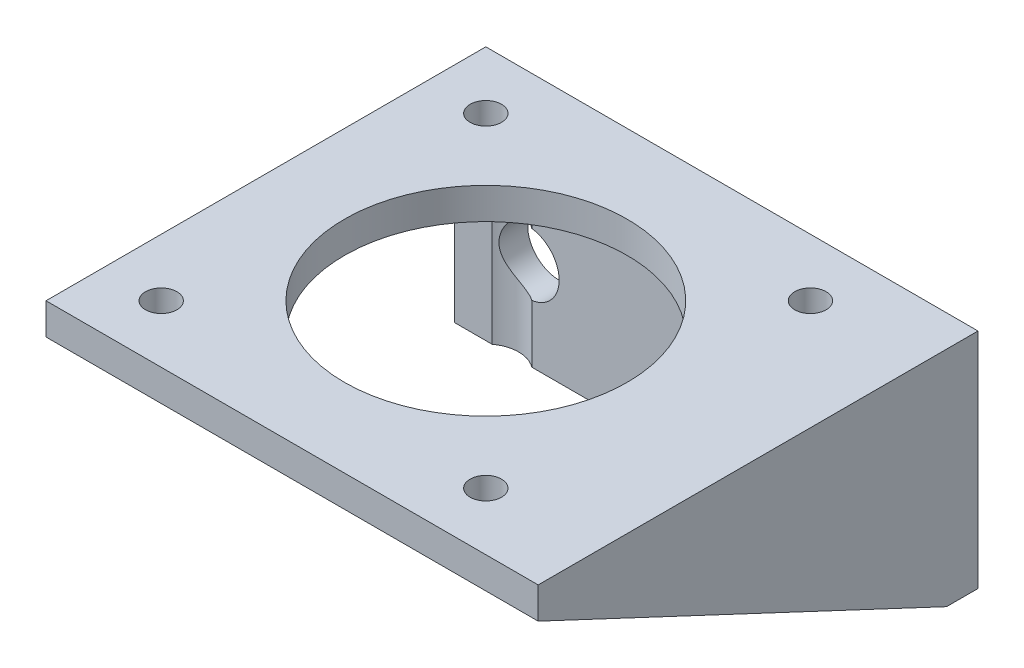
from build123d import *

# Parameters (mm, degrees)
SKETCH1_W           = 42
SKETCH1_H           = 21.3
BOSS_EXTRUDE1_DEPTH = 3
SKETCH2_R           = 3
CUT_EXTRUDE1_DEPTH  = 3
SKETCH4_W           = 42
SKETCH4_H           = 42
SKETCH4_R           = 1.5
SKETCH4_R_2         = 13.5
BOSS_EXTRUDE2_DEPTH = 3
BOSS_EXTRUDE3_DEPTH = 5
SKETCH6_R           = 3.134349401
CUT_EXTRUDE2_DEPTH  = 20


with BuildPart() as part:
    # Sketch1 → Boss-Extrude1 (new body)
    with BuildSketch(Plane.XY):
        with Locations((98.144783915, 168.215968794)):
            Rectangle(SKETCH1_W, SKETCH1_H)
    extrude(amount=BOSS_EXTRUDE1_DEPTH)

    # Sketch2 → Cut-Extrude1 (cut)
    with BuildSketch(Plane.XY.offset(3)):
        with Locations((112.144783915, 166.065968794)):
            Circle(SKETCH2_R)
        with Locations((84.144783915, 166.065968794)):
            Circle(SKETCH2_R)
    extrude(amount=-CUT_EXTRUDE1_DEPTH, mode=Mode.SUBTRACT)

    # Sketch4 → Boss-Extrude2 (add)
    with BuildSketch(Plane(origin=(0, 178.865968794, 0), x_dir=(-1, 0, 0), z_dir=(0, 1, 0))):
        with Locations((-98.144783915, 21)):
            Rectangle(SKETCH4_W, SKETCH4_H)
        with Locations((-113.644783915, 36.500179206)):
            Circle(SKETCH4_R, mode=Mode.SUBTRACT)
        with Locations((-82.644783915, 36.500179206)):
            Circle(SKETCH4_R, mode=Mode.SUBTRACT)
        with Locations((-82.644783915, 5.500179206)):
            Circle(SKETCH4_R, mode=Mode.SUBTRACT)
        with Locations((-113.644783915, 5.500179206)):
            Circle(SKETCH4_R, mode=Mode.SUBTRACT)
        with Locations((-98.144783915, 21.000179206)):
            Circle(SKETCH4_R_2, mode=Mode.SUBTRACT)
    extrude(amount=-BOSS_EXTRUDE2_DEPTH)

    # Sketch5 → Boss-Extrude3 (add)
    with BuildSketch(Plane(origin=(119.144783915, 0, 0), x_dir=(0, 0, -1), z_dir=(1, 0, 0))):
        Polygon((0, 157.565968794), (0, 178.865968794), (-42, 178.865968794), (-42, 175.865968794), (-3, 157.565968794), align=None)
    extrude(amount=BOSS_EXTRUDE3_DEPTH)

    # Sketch6 → Cut-Extrude2 (cut)
    with BuildSketch(Plane.XZ.offset(-175.865968794)):
        with Locations((82.644783915, 5.500179206)):
            Circle(SKETCH6_R)
        with Locations((113.644783915, 5.500179206)):
            Circle(SKETCH6_R)
    extrude(amount=CUT_EXTRUDE2_DEPTH, mode=Mode.SUBTRACT)


solid = part.part
